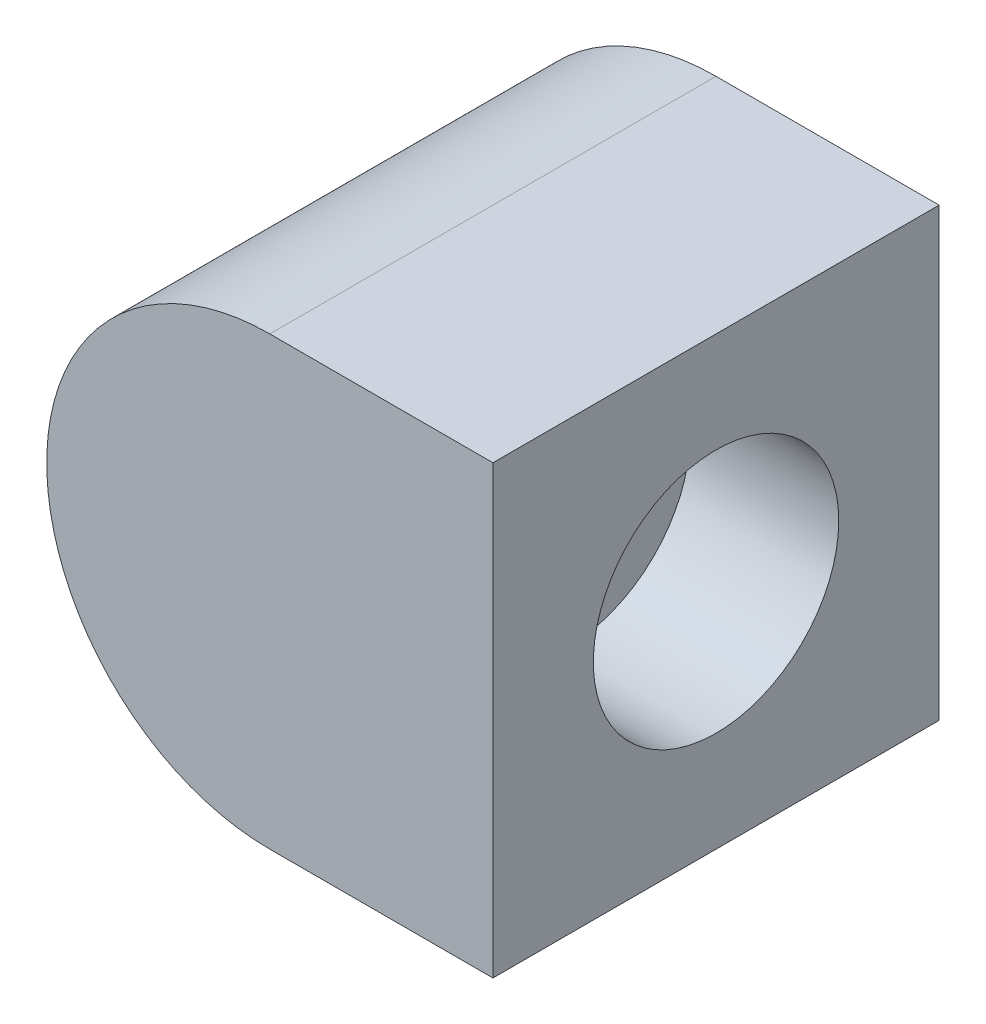
from build123d import *

# Parameters (mm, degrees)
RESSALTO_EXTRUS_O1_DEPTH = 6
ESBO_O3_R                = 1.65
CORTE_EXTRUS_O1_DEPTH    = 2


with BuildPart() as part:
    # Esboço1 → Ressalto-extrusão1 (new body)
    with BuildSketch(Plane.XY):
        with BuildLine():
            Line((0, 3), (3, 3))
            Line((3, 3), (3, -3))
            Line((3, -3), (0, -3))
            ThreePointArc((0, -3), (-3, 0), (0, 3))
        make_face()
    extrude(amount=RESSALTO_EXTRUS_O1_DEPTH)

    # Esboço3 → Corte-extrusão1 (cut)
    with BuildSketch(Plane(origin=(3, 0, 0), x_dir=(0, 0, -1), z_dir=(1, 0, 0))):
        with Locations((-3, 0)):
            Circle(ESBO_O3_R)
    extrude(amount=-CORTE_EXTRUS_O1_DEPTH, mode=Mode.SUBTRACT)


solid = part.part
